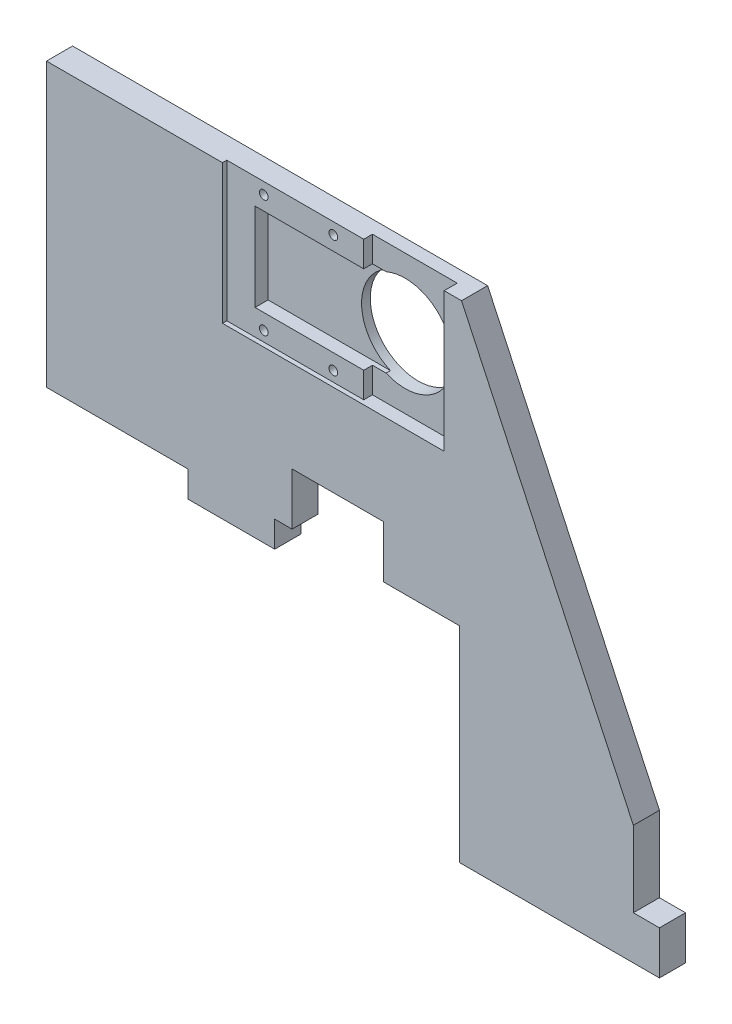
from build123d import *

# Parameters (mm, degrees)
ESQUISSE1_W             = 135
ESQUISSE1_H             = 112.17
BOSS_EXTRU_1_DEPTH      = 6
ENL_V_MAT_EXTRU_1_DEPTH = 6
ESQUISSE3_W             = 6
ESQUISSE3_H             = 10
ESQUISSE3_W_2           = 20
ESQUISSE3_H_2           = 6
BOSS_EXTRU_2_DEPTH      = 6
ESQUISSE4_W             = 51
ESQUISSE4_H             = 32
ENL_V_MAT_EXTRU_2_DEPTH = 3
ESQUISSE5_R             = 11
ENL_V_MAT_EXTRU_3_DEPTH = 4
ESQUISSE6_W             = 30
ESQUISSE6_H             = 20.2
ENL_V_MAT_EXTRU_4_DEPTH = 1
ESQUISSE7_W             = 25
ESQUISSE7_H             = 5.9
BOSS_EXTRU_3_DEPTH      = 2
ESQUISSE8_W             = 25
ESQUISSE8_H             = 5.9
BOSS_EXTRU_4_DEPTH      = 2
ESQUISSE9_W             = 6.5
ESQUISSE9_H             = 32
BOSS_EXTRU_5_DEPTH      = 2
ESQUISSE10_R            = 1
ENL_V_MAT_EXTRU_5_DEPTH = 6
ESQUISSE11_W            = 21
ESQUISSE11_H            = 12
ENL_V_MAT_EXTRU_6_DEPTH = 6


with BuildPart() as part:
    # Esquisse1 → Boss.-Extru.1 (new body)
    with BuildSketch(Plane.XY):
        Rectangle(ESQUISSE1_W, ESQUISSE1_H)
    extrude(amount=BOSS_EXTRU_1_DEPTH)

    # Esquisse2 → Enlèv. mat.-Extru.1 (cut)
    with BuildSketch(Plane.XY.offset(6)):
        Polygon((27.5, -56.085), (-67.5, -56.085), (-67.5, -8.915), (-38.5, -8.915), (27.5, -8.915), align=None)
        Polygon((67.5, -28.665), (27.980425971, 56.085), (67.5, 56.085), align=None)
    extrude(amount=-ENL_V_MAT_EXTRU_1_DEPTH, mode=Mode.SUBTRACT)

    # Esquisse3 → Boss.-Extru.2 (add)
    with BuildSketch(Plane.XY.offset(6)):
        with Locations((70.5, -51.085)):
            Rectangle(ESQUISSE3_W, ESQUISSE3_H)
        with Locations((-25, -11.915)):
            Rectangle(ESQUISSE3_W_2, ESQUISSE3_H_2)
    extrude(amount=-BOSS_EXTRU_2_DEPTH)

    # Esquisse4 → Enlèv. mat.-Extru.2 (cut)
    with BuildSketch(Plane.XY.offset(6)):
        with Locations((-1.519574029, 40.085)):
            Rectangle(ESQUISSE4_W, ESQUISSE4_H)
    extrude(amount=-ENL_V_MAT_EXTRU_2_DEPTH, mode=Mode.SUBTRACT)

    # Esquisse5 → Enlèv. mat.-Extru.3 (cut, through all)
    with BuildSketch(Plane.XY.offset(3)):
        with Locations((11.980425971, 40.085)):
            Circle(ESQUISSE5_R)
    extrude(amount=-ENL_V_MAT_EXTRU_3_DEPTH, mode=Mode.SUBTRACT)

    # Esquisse6 → Enlèv. mat.-Extru.4 (cut)
    with BuildSketch(Plane.XY.offset(3)):
        with Locations((-5.519574029, 40.085)):
            Rectangle(ESQUISSE6_W, ESQUISSE6_H)
    extrude(amount=-ENL_V_MAT_EXTRU_4_DEPTH, mode=Mode.SUBTRACT)

    # Esquisse7 → Boss.-Extru.3 (add)
    with BuildSketch(Plane.XY.offset(3)):
        with Locations((-8.019574029, 53.135)):
            Rectangle(ESQUISSE7_W, ESQUISSE7_H)
    extrude(amount=BOSS_EXTRU_3_DEPTH)

    # Esquisse8 → Boss.-Extru.4 (add)
    with BuildSketch(Plane.XY.offset(3)):
        with Locations((-8.019574029, 27.035)):
            Rectangle(ESQUISSE8_W, ESQUISSE8_H)
    extrude(amount=BOSS_EXTRU_4_DEPTH)

    # Esquisse9 → Boss.-Extru.5 (add)
    with BuildSketch(Plane.XY.offset(3)):
        with Locations((-23.769574029, 40.085)):
            Rectangle(ESQUISSE9_W, ESQUISSE9_H)
    extrude(amount=BOSS_EXTRU_5_DEPTH)

    # Esquisse10 → Enlèv. mat.-Extru.5 (cut, through all)
    with BuildSketch(Plane.XY.offset(5)):
        with Locations((-18.519574029, 53.435)):
            Circle(ESQUISSE10_R)
        with Locations((-2.519574029, 53.435)):
            Circle(ESQUISSE10_R)
        with Locations((-18.519574029, 26.435)):
            Circle(ESQUISSE10_R)
        with Locations((-2.519574029, 26.435)):
            Circle(ESQUISSE10_R)
    extrude(amount=-ENL_V_MAT_EXTRU_5_DEPTH, mode=Mode.SUBTRACT)

    # Esquisse11 → Enlèv. mat.-Extru.6 (cut)
    with BuildSketch(Plane.XY.offset(6)):
        with Locations((-0.5, -2.915)):
            Rectangle(ESQUISSE11_W, ESQUISSE11_H)
    extrude(amount=-ENL_V_MAT_EXTRU_6_DEPTH, mode=Mode.SUBTRACT)


solid = part.part
